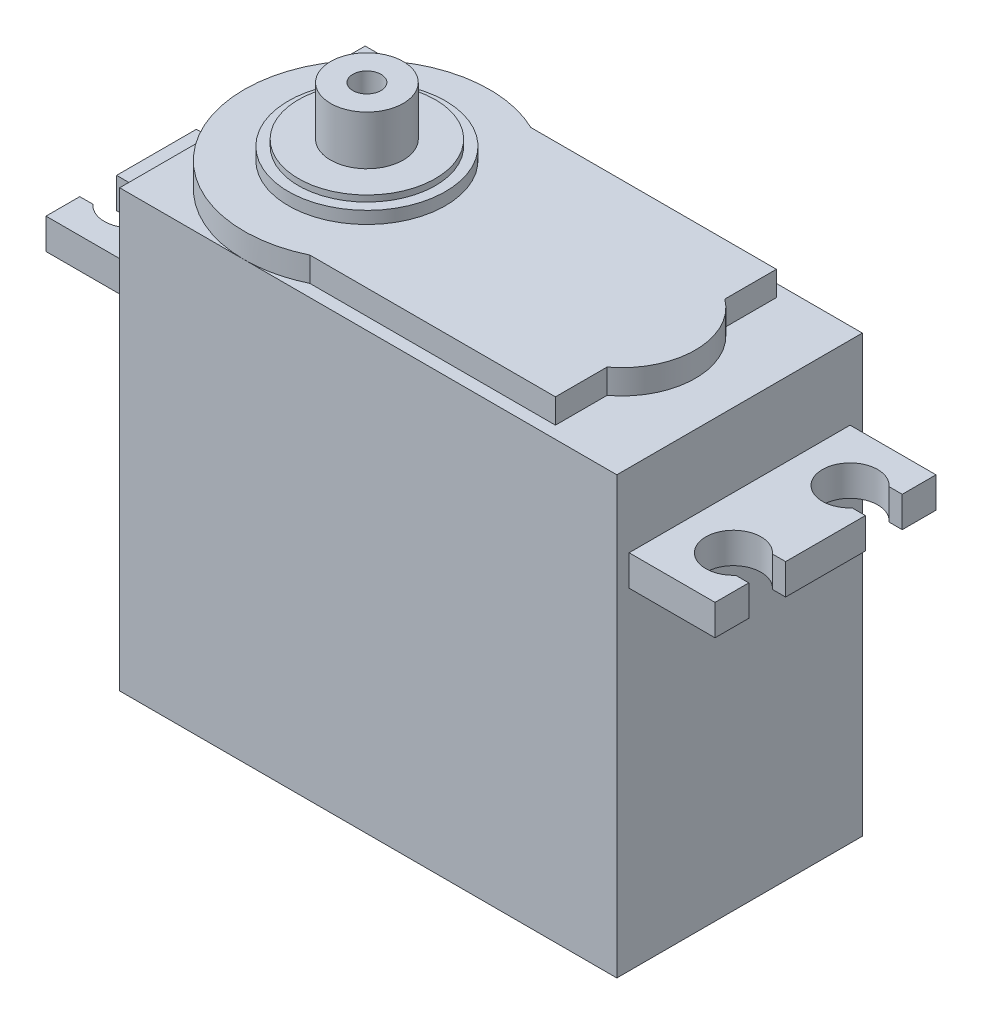
from build123d import *

# Parameters (mm, degrees)
ESBO_O1_W                = 40.5
ESBO_O1_H                = 35.5
RESSALTO_EXTRUS_O1_DEPTH = 20
RESSALTO_EXTRUS_O2_DEPTH = 2
ESBO_O3_W                = 18
ESBO_O3_H                = 2.499999999
RESSALTO_EXTRUS_O3_DEPTH = 7
CORTE_EXTRUS_O1_DEPTH    = 11.500000003
CORTE_EXTRUS_O2_DEPTH    = 11.500000003
RESSALTO_EXTRUS_O4_DEPTH = 2
ESBO_O7_W                = 18
ESBO_O7_H                = 2.499999994
RESSALTO_EXTRUS_O5_DEPTH = 7
CORTE_EXTRUS_O3_DEPTH    = 30.499999991
CORTE_EXTRUS_O4_DEPTH    = 30.499999991
ESBO_O10_W               = 2.25
ESBO_O10_H               = 2.5
ESBO_O11_W               = 2.25
ESBO_O11_H               = 2.5
ESBO_O12_W               = 2.25
ESBO_O12_H               = 2.5
ESBO_O13_W               = 2.25
ESBO_O13_H               = 2.5
ESBO_O15_R               = 2.96
ESBO_O15_R_2             = 1.15
RESSALTO_EXTRUS_O6_DEPTH = 4


with BuildPart() as part:
    # Esboço1 → Ressalto-extrusão1 (new body)
    with BuildSketch(Plane(origin=(0, 0, -10), x_dir=(-1, 0, 0), z_dir=(0, 0, -1))):
        with Locations((0, 17.75)):
            Rectangle(ESBO_O1_W, ESBO_O1_H)
    extrude(amount=-RESSALTO_EXTRUS_O1_DEPTH)

    # Esboço2 → Ressalto-extrusão2 (add)
    with BuildSketch(Plane(origin=(0, 35.5, 0), x_dir=(-1, 0, 0), z_dir=(0, 1, 0))):
        with BuildLine():
            Line((-14.25, 9), (5.75, 9))
            ThreePointArc((5.75, 9), (20.108898944, -1e-09), (5.75, -9))
            Line((5.75, -9), (-14.25, -9))
            Line((-14.25, -9), (-14.25, 9))
        make_face()
    extrude(amount=RESSALTO_EXTRUS_O2_DEPTH)

    # Esboço3 → Ressalto-extrusão3 (add)
    with BuildSketch(Plane(origin=(20.25, 0, 0), x_dir=(0, 0, -1), z_dir=(1, 0, 0))):
        with Locations((0, 28.249999997)):
            Rectangle(ESBO_O3_W, ESBO_O3_H)
    extrude(amount=RESSALTO_EXTRUS_O3_DEPTH)

    # Esboço4 → Corte-extrusão1 (cut, through all)
    with BuildSketch(Plane.XZ.offset(-26.999999997)):
        with BuildLine():
            Line((27.25, 3.25), (27.25, 6.25))
            Line((27.25, 6.25), (26.177050983, 6.25))
            ThreePointArc((26.177050983, 6.25), (26.75, 4.75), (26.177050983, 3.25))
            Line((26.177050983, 3.25), (27.25, 3.25))
        make_face()
    extrude(amount=-CORTE_EXTRUS_O1_DEPTH, mode=Mode.SUBTRACT)

    # Esboço5 → Corte-extrusão2 (cut, through all)
    with BuildSketch(Plane.XZ.offset(-26.999999997)):
        with BuildLine():
            Line((27.25, -6.25), (27.25, -3.25))
            Line((27.25, -3.25), (26.177050983, -3.25))
            ThreePointArc((26.177050983, -3.25), (26.75, -4.75), (26.177050983, -6.25))
            Line((26.177050983, -6.25), (27.25, -6.25))
        make_face()
    extrude(amount=-CORTE_EXTRUS_O2_DEPTH, mode=Mode.SUBTRACT)

    # Esboço6 → Ressalto-extrusão4 (add)
    with BuildSketch(Plane(origin=(0, 35.5, 0), x_dir=(-1, 0, 0), z_dir=(0, 1, 0))):
        with BuildLine():
            Line((-14.249999993, 4.8), (-14.249999993, -4.800000003))
            ThreePointArc((-14.249999993, -4.800000003), (-16.649999996, -1e-09), (-14.249999993, 4.8))
        make_face()
    extrude(amount=RESSALTO_EXTRUS_O4_DEPTH)

    # Esboço7 → Ressalto-extrusão5 (add)
    with BuildSketch(Plane.ZY.offset(20.25)):
        with Locations((0, 28.249999994)):
            Rectangle(ESBO_O7_W, ESBO_O7_H)
    extrude(amount=RESSALTO_EXTRUS_O5_DEPTH)

    # Esboço8 → Corte-extrusão3 (cut, through all)
    with BuildSketch(Plane(origin=(0, 29.499999991, 0), x_dir=(-1, 0, 0), z_dir=(0, 1, 0))):
        with BuildLine():
            Line((27.25, 6.25), (26.177050983, 6.25))
            ThreePointArc((26.177050983, 6.25), (26.75, 4.75), (26.177050983, 3.25))
            Line((26.177050983, 3.25), (27.25, 3.25))
            Line((27.25, 3.25), (27.25, 6.25))
        make_face()
    extrude(amount=-CORTE_EXTRUS_O3_DEPTH, mode=Mode.SUBTRACT)

    # Esboço9 → Corte-extrusão4 (cut, through all)
    with BuildSketch(Plane(origin=(0, 29.499999991, 0), x_dir=(-1, 0, 0), z_dir=(0, 1, 0))):
        with BuildLine():
            Line((27.25, -6.25), (27.25, -3.25))
            Line((27.25, -3.25), (26.177050983, -3.25))
            ThreePointArc((26.177050983, -3.25), (26.75, -4.75), (26.177050983, -6.25))
            Line((26.177050983, -6.25), (27.25, -6.25))
        make_face()
    extrude(amount=-CORTE_EXTRUS_O4_DEPTH, mode=Mode.SUBTRACT)

    # Esboço10 → Corte-Revolução1 (revolve, cut)
    with BuildSketch(Plane.XY.offset(4.75)):
        with Locations((-23.375, 28.25)):
            Rectangle(ESBO_O10_W, ESBO_O10_H)
    revolve(axis=Axis((-24.5, 29.5, 4.75), (0, -1, 0)), mode=Mode.SUBTRACT)

    # Esboço11 → Corte-Revolução2 (revolve, cut)
    with BuildSketch(Plane.XY.offset(-4.75)):
        with Locations((-23.375, 28.25)):
            Rectangle(ESBO_O11_W, ESBO_O11_H)
    revolve(axis=Axis((-24.5, 29.5, -4.75), (0, -1, 0)), mode=Mode.SUBTRACT)

    # Esboço12 → Corte-Revolução3 (revolve, cut)
    with BuildSketch(Plane.XY.offset(-4.75)):
        with Locations((25.625, 28.25)):
            Rectangle(ESBO_O12_W, ESBO_O12_H)
    revolve(axis=Axis((24.5, 29.5, -4.75), (0, -1, 0)), mode=Mode.SUBTRACT)

    # Esboço13 → Corte-Revolução4 (revolve, cut)
    with BuildSketch(Plane.XY.offset(4.75)):
        with Locations((25.625, 28.25)):
            Rectangle(ESBO_O13_W, ESBO_O13_H)
    revolve(axis=Axis((24.5, 29.5, 4.75), (0, -1, 0)), mode=Mode.SUBTRACT)

    # Esboço14 → Revolução1 (revolve)
    with BuildSketch(Plane.XY):
        Polygon((-4.533898944, 39), (-10.108898944, 39), (-10.108898944, 37.5), (-3.708898944, 37.5), (-3.708898944, 38.5), (-4.533898944, 38.5), align=None)
    revolve(axis=Axis((-10.108898944, 39, 0), (0, -1, 0)))

    # Esboço15 → Ressalto-extrusão6 (add)
    with BuildSketch(Plane(origin=(0, 39, 0), x_dir=(1, 0, 0), z_dir=(0, 1, 0))):
        with Locations((-10.108898944, 0)):
            Circle(ESBO_O15_R)
        with Locations((-10.108898944, 0)):
            Circle(ESBO_O15_R_2, mode=Mode.SUBTRACT)
    extrude(amount=RESSALTO_EXTRUS_O6_DEPTH)


solid = part.part
